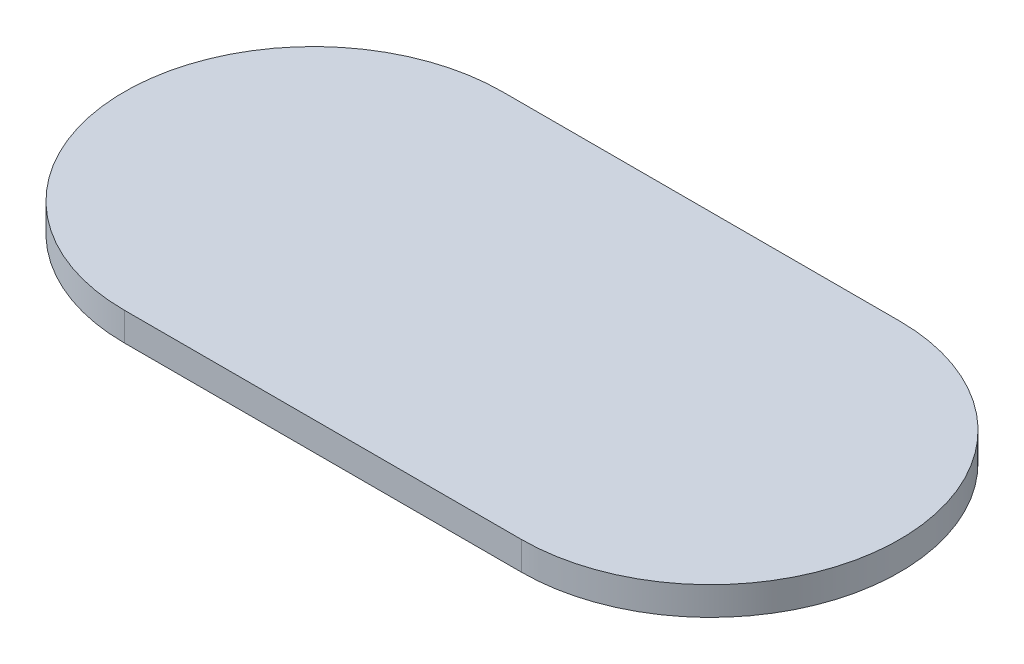
from build123d import *

# Parameters (mm, degrees)
BOSS_EXTRUDE1_DEPTH = 3.81


with BuildPart() as part:
    # Sketch1 → Boss-Extrude1 (new body)
    with BuildSketch(Plane(origin=(0, 0, 0), x_dir=(1, 0, 0), z_dir=(0, 1, 0))):
        with BuildLine():
            Line((-26.67, -25.4), (26.67, -25.4))
            ThreePointArc((26.67, -25.4), (52.07, 0), (26.67, 25.4))
            Line((26.67, 25.4), (-26.67, 25.4))
            ThreePointArc((-26.67, 25.4), (-52.07, 0), (-26.67, -25.4))
        make_face()
    extrude(amount=BOSS_EXTRUDE1_DEPTH)


solid = part.part
